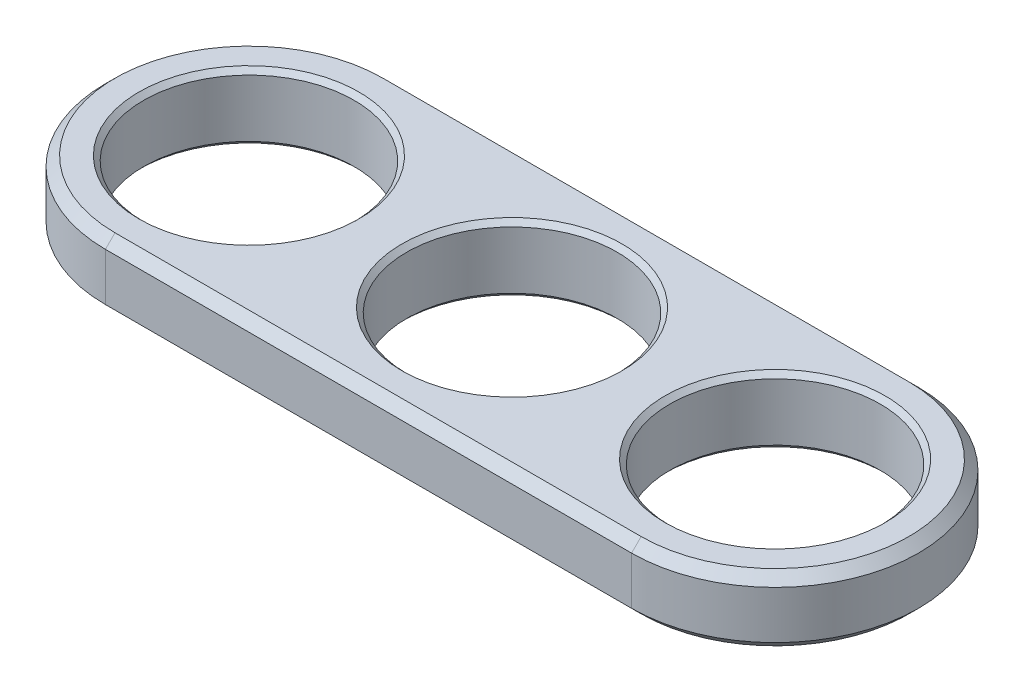
from build123d import *

# Parameters (mm, degrees)
ESQUISSE1_R        = 11
BOSS_EXTRU_1_DEPTH = 7
CHANFREIN1_SIZE    = 0.5
CHANFREIN2_SIZE    = 1


with BuildPart() as part:
    # Esquisse1 → Boss.-Extru.1 (new body)
    with BuildSketch(Plane(origin=(0, 0, 0), x_dir=(1, 0, 0), z_dir=(0, 1, 0))):
        with BuildLine():
            Line((0, 15), (55, 15))
            ThreePointArc((55, 15), (70, 0), (55, -15))
            Line((55, -15), (0, -15))
            ThreePointArc((0, -15), (-15, 0), (0, 15))
        make_face()
        with Locations(Location((27.5, 0, 0), (0, 0, 270))):  # turned: the seam where the file's is
            Circle(ESQUISSE1_R, mode=Mode.SUBTRACT)
        with Locations(Location((0, 0, 0), (0, 0, 270))):  # turned: the seam where the file's is
            Circle(ESQUISSE1_R, mode=Mode.SUBTRACT)
        with Locations(Location((55, 0, 0), (0, 0, 270))):  # turned: the seam where the file's is
            Circle(ESQUISSE1_R, mode=Mode.SUBTRACT)
    extrude(amount=BOSS_EXTRU_1_DEPTH)

    # Chanfrein1
    chanfrein1_edges = [part.edges().sort_by_distance(p)[0] for p in [
        (27.5, 0, -11),
        (27.5, 7, -11),
        (0, 0, -11),
        (0, 7, -11),
        (55, 0, -11),
        (55, 7, -11),
    ]]
    chamfer(chanfrein1_edges, length=CHANFREIN1_SIZE)

    # Chanfrein2
    chanfrein2_edges = [part.edges().sort_by_distance(p)[0] for p in [
        (70, 7, 0),
        (27.5, 7, -15),
        (-15, 7, 0),
        (27.5, 0, -15),
        (70, 0, 0),
        (27.5, 0, 15),
        (-15, 0, 0),
        (27.5, 7, 15),
    ]]
    chamfer(chanfrein2_edges, length=CHANFREIN2_SIZE)


solid = part.part
